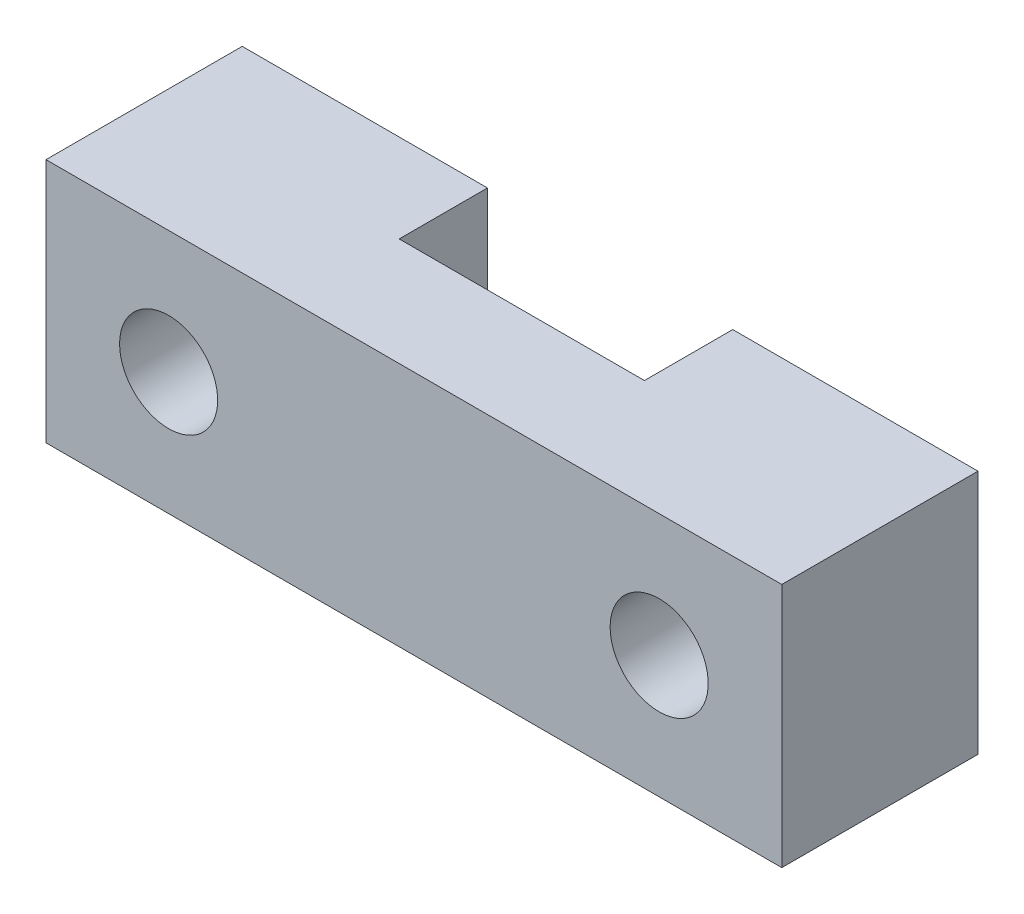
from build123d import *

# Parameters (mm, degrees)
ESQUISSE1_W             = 15
ESQUISSE1_H             = 4
BOSS_EXTRU_1_DEPTH      = 5
ESQUISSE2_W             = 5
ESQUISSE2_H             = 1.8
ENL_V_MAT_EXTRU_1_DEPTH = 5
ESQUISSE3_R             = 1
ENL_V_MAT_EXTRU_2_DEPTH = 5


with BuildPart() as part:
    # Esquisse1 → Boss.-Extru.1 (new body)
    with BuildSketch(Plane(origin=(0, 0, 0), x_dir=(1, 0, 0), z_dir=(0, 1, 0))):
        Rectangle(ESQUISSE1_W, ESQUISSE1_H)
    extrude(amount=BOSS_EXTRU_1_DEPTH)

    # Esquisse2 → Enlèv. mat.-Extru.1 (cut)
    with BuildSketch(Plane(origin=(0, 5, 0), x_dir=(1, 0, 0), z_dir=(0, 1, 0))):
        with Locations((0, 1.1)):
            Rectangle(ESQUISSE2_W, ESQUISSE2_H)
    extrude(amount=-ENL_V_MAT_EXTRU_1_DEPTH, mode=Mode.SUBTRACT)

    # Esquisse3 → Enlèv. mat.-Extru.2 (cut)
    with BuildSketch(Plane(origin=(0, 0, -2), x_dir=(-1, 0, 0), z_dir=(0, 0, -1))):
        with Locations((5, 2.5)):
            Circle(ESQUISSE3_R)
        with Locations((-5, 2.5)):
            Circle(ESQUISSE3_R)
    extrude(amount=-ENL_V_MAT_EXTRU_2_DEPTH, mode=Mode.SUBTRACT)


solid = part.part
